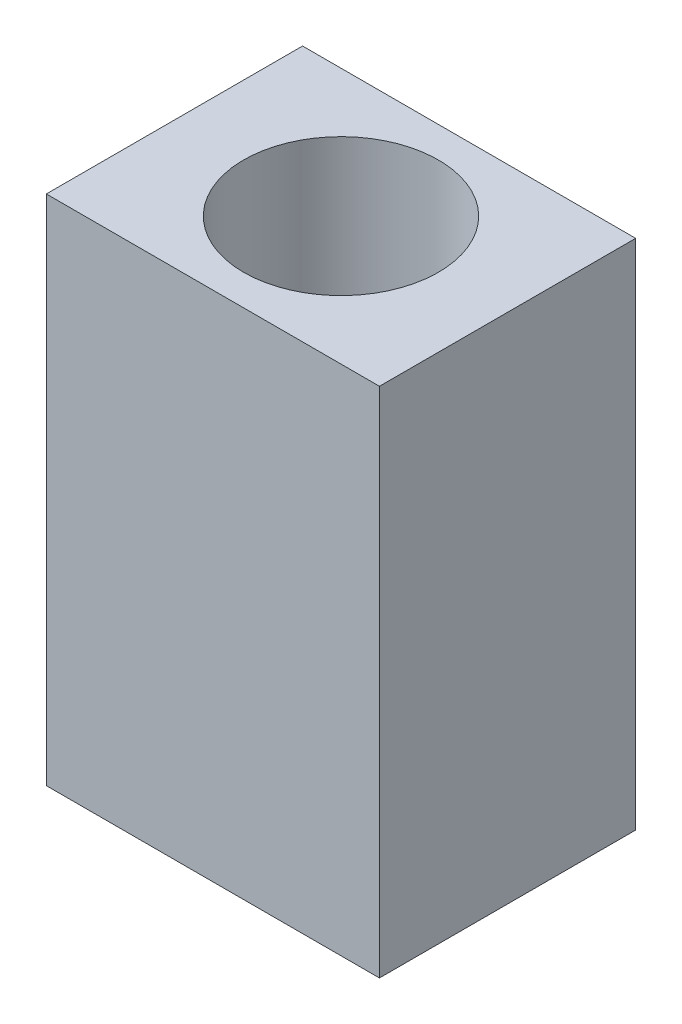
from build123d import *

# Parameters (mm, degrees)
SKETCH3_W           = 13
SKETCH3_H           = 20
BOSS_EXTRUDE1_DEPTH = 10
SKETCH4_R           = 3.8
CUT_EXTRUDE1_DEPTH  = 17


with BuildPart() as part:
    # Sketch3 → Boss-Extrude1 (new body)
    with BuildSketch(Plane.XY):
        with Locations((6.5, 10)):
            Rectangle(SKETCH3_W, SKETCH3_H)
    extrude(amount=BOSS_EXTRUDE1_DEPTH)

    # Sketch4 → Cut-Extrude1 (cut)
    with BuildSketch(Plane(origin=(0, 20, 0), x_dir=(1, 0, 0), z_dir=(0, 1, 0))):
        with Locations((6.5, -5)):
            Circle(SKETCH4_R)
    extrude(amount=-CUT_EXTRUDE1_DEPTH, mode=Mode.SUBTRACT)


solid = part.part
